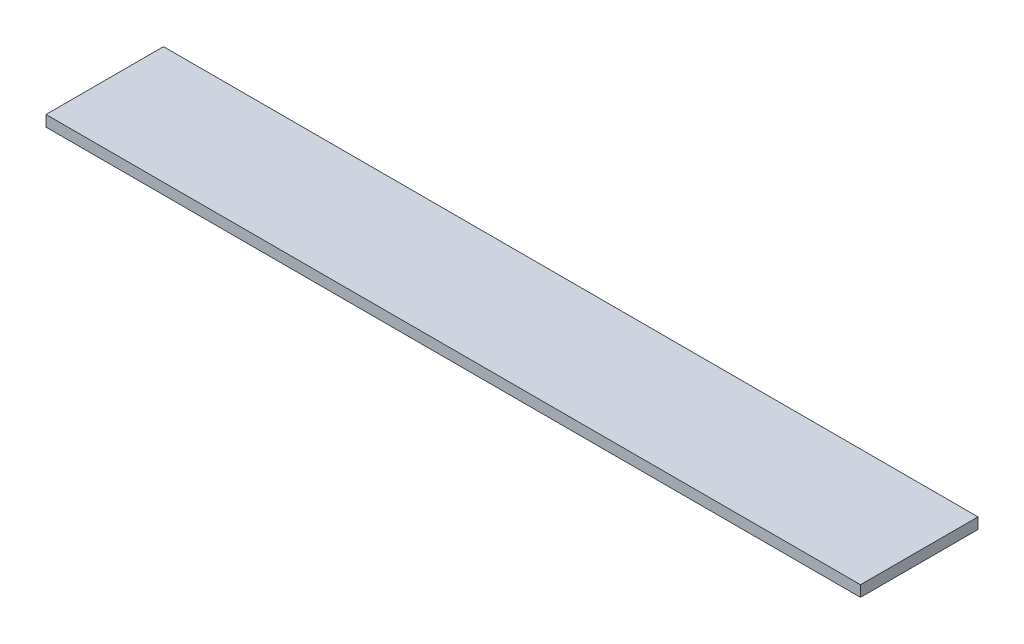
from build123d import *

# Parameters (mm, degrees)
SKETCH1_W           = 222.5
SKETCH1_H           = 32.1
BOSS_EXTRUDE1_DEPTH = 3


with BuildPart() as part:
    # Sketch1 → Boss-Extrude1 (new body)
    with BuildSketch(Plane(origin=(0, 0, 0), x_dir=(1, 0, 0), z_dir=(0, 1, 0))):
        with Locations((-111.25, 16.05)):
            Rectangle(SKETCH1_W, SKETCH1_H)
    extrude(amount=BOSS_EXTRUDE1_DEPTH)


solid = part.part
